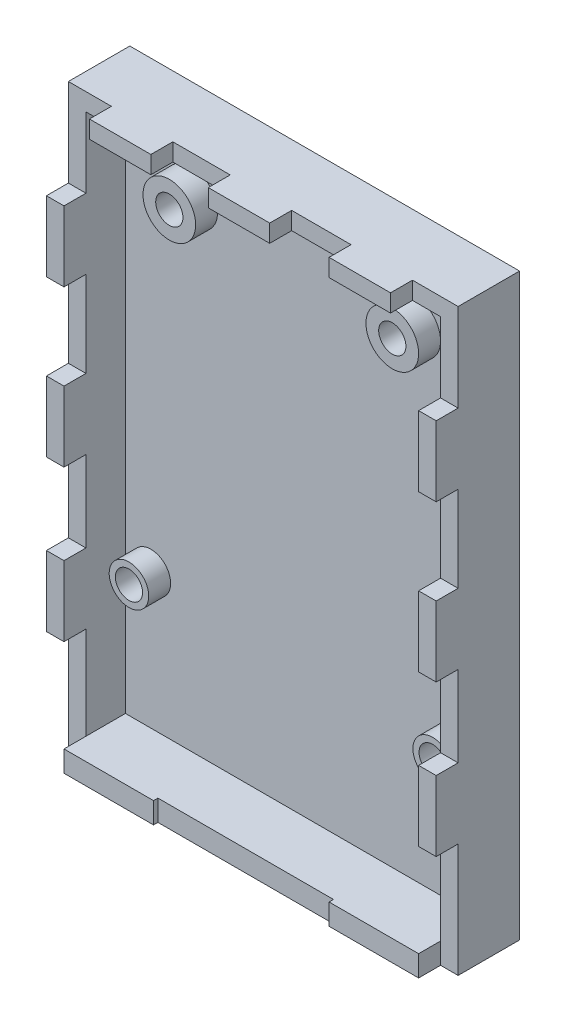
from build123d import *

# Parameters (mm, degrees)
ESBO_O1_W                = 44.4
ESBO_O1_H                = 66
RESSALTO_EXTRUS_O1_DEPTH = 2.5
ESBO_O1_3_R              = 3
ESBO_O1_3_R_2            = 1.55
ESBO_O1_3_R_3            = 2.25
RESSALTO_EXTRUS_O2_DEPTH = 5
ESBO_O1_4_W              = 20
ESBO_O1_4_H              = 2.4
RESSALTO_EXTRUS_O3_DEPTH = 9
ESBO_O1_5_W              = 2
ESBO_O1_5_H              = 8
ESBO_O1_5_H_2            = 9.779719316
ESBO_O1_5_H_3            = 9.220608646
ESBO_O1_5_W_2            = 10.2
ESBO_O1_5_H_4            = 2.4
ESBO_O1_5_W_3            = 7
ESBO_O1_5_H_5            = 2
ESBO_O1_5_W_4            = 6.764123849
ESBO_O1_5_W_5            = 6.535876151
RESSALTO_EXTRUS_O4_DEPTH = 7
ESBO_O1_6_W              = 2
ESBO_O1_6_H              = 8
ESBO_O1_6_W_2            = 10.2
ESBO_O1_6_H_2            = 2.4
ESBO_O1_6_W_3            = 7
ESBO_O1_6_H_3            = 2
RESSALTO_EXTRUS_O5_DEPTH = 9.5


with BuildPart() as part:
    # Esboço1 → Ressalto-extrusão1 (new body)
    with BuildSketch(Plane.XY):
        with Locations((-2.493970888, -16.665150932)):
            Rectangle(ESBO_O1_W, ESBO_O1_H)
    extrude(amount=RESSALTO_EXTRUS_O1_DEPTH)

    # Esboço1<3> → Ressalto-extrusão2 (add)
    with BuildSketch(Plane.XY):
        with Locations((-15.193970888, 7.434849068)):
            Circle(ESBO_O1_3_R)
        with Locations((-15.193970888, 7.434849068)):
            Circle(ESBO_O1_3_R_2, mode=Mode.SUBTRACT)
        with Locations((10.206029112, 7.434849068)):
            Circle(ESBO_O1_3_R)
        with Locations((10.206029112, 7.434849068)):
            Circle(ESBO_O1_3_R_2, mode=Mode.SUBTRACT)
        with Locations((-19.793970888, -31.865150932)):
            Circle(ESBO_O1_3_R_3)
        with Locations((-19.793970888, -31.865150932)):
            Circle(ESBO_O1_3_R_2, mode=Mode.SUBTRACT)
        with Locations((14.806029112, -31.865150932)):
            Circle(ESBO_O1_3_R_3)
        with Locations((14.806029112, -31.865150932)):
            Circle(ESBO_O1_3_R_2, mode=Mode.SUBTRACT)
    extrude(amount=RESSALTO_EXTRUS_O2_DEPTH)

    # Esboço1<4> → Ressalto-extrusão3 (add)
    with BuildSketch(Plane.XY):
        with Locations((-2.493970888, -48.465150932)):
            Rectangle(ESBO_O1_4_W, ESBO_O1_4_H)
    extrude(amount=RESSALTO_EXTRUS_O3_DEPTH)

    # Esboço1<5> → Ressalto-extrusão4 (add)
    with BuildSketch(Plane.XY):
        Polygon((-24.693970888, 16.334849068), (-24.693970888, 6.311482938), (-22.693970888, 6.311482938), (-22.693970888, 14.334849068), (-19.793970888, 14.334849068), (-19.793970888, 16.334849068), align=None)
        with Locations((-23.693970888, 2.311482938)):
            Rectangle(ESBO_O1_5_W, ESBO_O1_5_H)
        with Locations((-23.693970888, -6.57837672)):
            Rectangle(ESBO_O1_5_W, ESBO_O1_5_H_2)
        with Locations((-23.693970888, -15.468236378)):
            Rectangle(ESBO_O1_5_W, ESBO_O1_5_H)
        with Locations((-23.693970888, -24.078540701)):
            Rectangle(ESBO_O1_5_W, ESBO_O1_5_H_3)
        with Locations((-23.693970888, -32.688845024)):
            Rectangle(ESBO_O1_5_W, ESBO_O1_5_H)
        Polygon((-24.693970888, -49.665150932), (-22.693970888, -49.665150932), (-22.693970888, -47.265150932), (-22.693970888, -36.688845024), (-24.693970888, -36.688845024), align=None)
        with Locations((-17.593970888, -48.465150932)):
            Rectangle(ESBO_O1_5_W_2, ESBO_O1_5_H_4)
        with Locations((12.606029112, -48.465150932)):
            Rectangle(ESBO_O1_5_W_2, ESBO_O1_5_H_4)
        Polygon((17.706029112, -47.265150932), (17.706029112, -49.665150932), (19.706029112, -49.665150932), (19.706029112, -36.688845024), (17.706029112, -36.688845024), align=None)
        with Locations((18.706029112, -32.688845024)):
            Rectangle(ESBO_O1_5_W, ESBO_O1_5_H)
        with Locations((18.706029112, -24.078540701)):
            Rectangle(ESBO_O1_5_W, ESBO_O1_5_H_3)
        with Locations((18.706029112, -15.468236378)):
            Rectangle(ESBO_O1_5_W, ESBO_O1_5_H)
        with Locations((18.706029112, -6.57837672)):
            Rectangle(ESBO_O1_5_W, ESBO_O1_5_H_2)
        with Locations((18.706029112, 2.311482938)):
            Rectangle(ESBO_O1_5_W, ESBO_O1_5_H)
        Polygon((17.706029112, 14.334849068), (17.706029112, 6.311482938), (19.706029112, 6.311482938), (19.706029112, 16.334849068), (14.506029112, 16.334849068), (14.506029112, 14.334849068), align=None)
        with Locations((11.006029112, 15.334849068)):
            Rectangle(ESBO_O1_5_W_3, ESBO_O1_5_H_5)
        with Locations((4.123967187, 15.334849068)):
            Rectangle(ESBO_O1_5_W_4, ESBO_O1_5_H_5)
        with Locations((-2.758094737, 15.334849068)):
            Rectangle(ESBO_O1_5_W_3, ESBO_O1_5_H_5)
        with Locations((-9.526032813, 15.334849068)):
            Rectangle(ESBO_O1_5_W_5, ESBO_O1_5_H_5)
        with Locations((-16.293970888, 15.334849068)):
            Rectangle(ESBO_O1_5_W_3, ESBO_O1_5_H_5)
    extrude(amount=RESSALTO_EXTRUS_O4_DEPTH)

    # Esboço1<6> → Ressalto-extrusão5 (add)
    with BuildSketch(Plane.XY):
        with Locations((-23.693970888, 2.311482938)):
            Rectangle(ESBO_O1_6_W, ESBO_O1_6_H)
        with Locations((-23.693970888, -15.468236378)):
            Rectangle(ESBO_O1_6_W, ESBO_O1_6_H)
        with Locations((-23.693970888, -32.688845024)):
            Rectangle(ESBO_O1_6_W, ESBO_O1_6_H)
        with Locations((-17.593970888, -48.465150932)):
            Rectangle(ESBO_O1_6_W_2, ESBO_O1_6_H_2)
        with Locations((12.606029112, -48.465150932)):
            Rectangle(ESBO_O1_6_W_2, ESBO_O1_6_H_2)
        with Locations((18.706029112, -32.688845024)):
            Rectangle(ESBO_O1_6_W, ESBO_O1_6_H)
        with Locations((18.706029112, -15.468236378)):
            Rectangle(ESBO_O1_6_W, ESBO_O1_6_H)
        with Locations((18.706029112, 2.311482938)):
            Rectangle(ESBO_O1_6_W, ESBO_O1_6_H)
        with Locations((11.006029112, 15.334849068)):
            Rectangle(ESBO_O1_6_W_3, ESBO_O1_6_H_3)
        with Locations((-2.758094737, 15.334849068)):
            Rectangle(ESBO_O1_6_W_3, ESBO_O1_6_H_3)
        with Locations((-16.293970888, 15.334849068)):
            Rectangle(ESBO_O1_6_W_3, ESBO_O1_6_H_3)
    extrude(amount=RESSALTO_EXTRUS_O5_DEPTH)


solid = part.part
